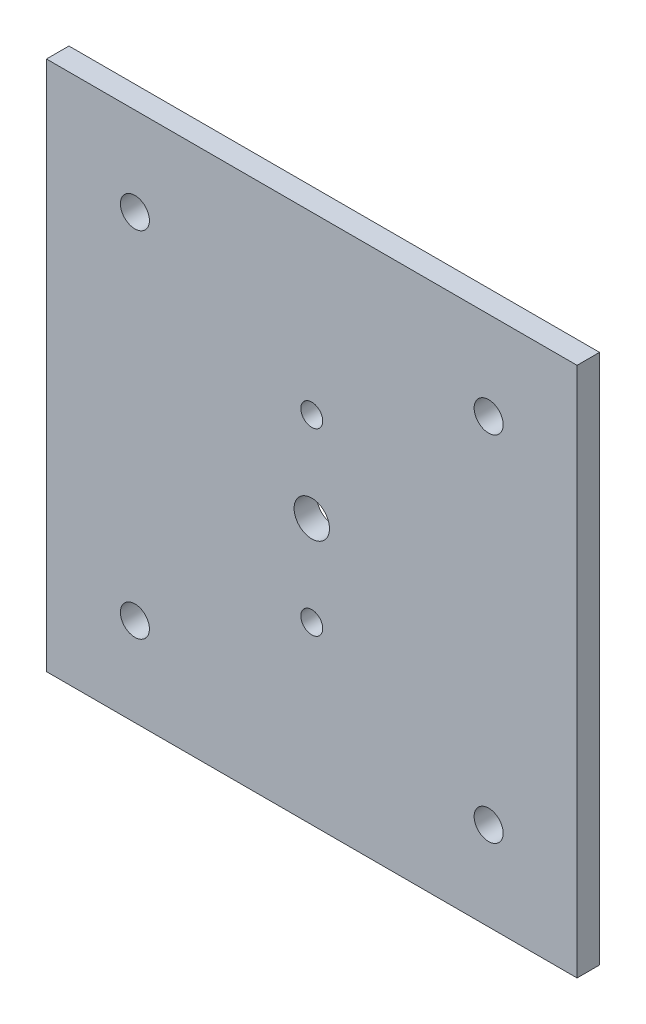
from build123d import *

# Parameters (mm, degrees)
CROQUIS1_W              = 150
CROQUIS1_H              = 150
CROQUIS1_R              = 3.1
CROQUIS1_R_2            = 4.1
CROQUIS1_R_3            = 5
SALIENTE_EXTRUIR1_DEPTH = 6.35


with BuildPart() as part:
    # Croquis1 → Saliente-Extruir1 (new body)
    with BuildSketch(Plane.XY):
        Rectangle(CROQUIS1_W, CROQUIS1_H)
        with Locations((0, 25.4)):
            Circle(CROQUIS1_R, mode=Mode.SUBTRACT)
        with Locations((0, -25.4)):
            Circle(CROQUIS1_R, mode=Mode.SUBTRACT)
        with Locations((-50, 50)):
            Circle(CROQUIS1_R_2, mode=Mode.SUBTRACT)
        with Locations((50, 50)):
            Circle(CROQUIS1_R_2, mode=Mode.SUBTRACT)
        with Locations((50, -50)):
            Circle(CROQUIS1_R_2, mode=Mode.SUBTRACT)
        with Locations((-50, -50)):
            Circle(CROQUIS1_R_2, mode=Mode.SUBTRACT)
        Circle(CROQUIS1_R_3, mode=Mode.SUBTRACT)
    extrude(amount=SALIENTE_EXTRUIR1_DEPTH)


solid = part.part
